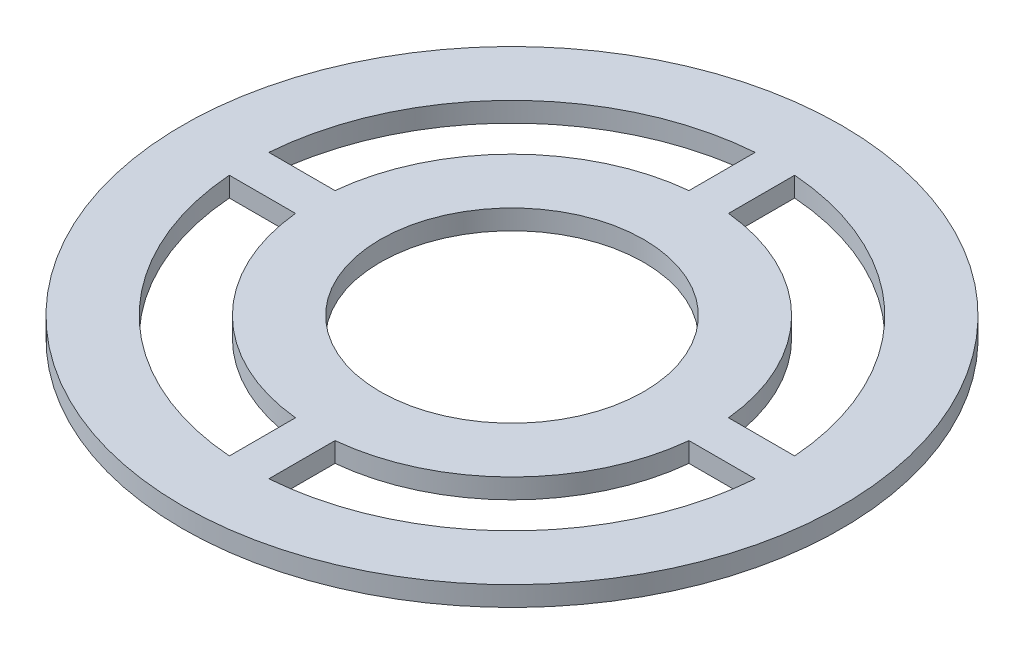
from build123d import *

# Parameters (mm, degrees)
ESQUISSE1_R          = 25
ESQUISSE1_R_2        = 20
BOSS_EXTRU_3_DEPTH   = 1.5
ESQUISSE1_R_3        = 15
ESQUISSE1_R_4        = 10
BOSS_EXTRU_3_2_DEPTH = 1.5
ESQUISSE3_W          = 7
ESQUISSE3_H          = 3
ESQUISSE3_W_2        = 3
ESQUISSE3_H_2        = 7
BOSS_EXTRU_5_DEPTH   = 1.5


with BuildPart() as part:
    # Esquisse1 → Boss.-Extru.3 (new body)
    with BuildSketch(Plane(origin=(0, 0, 0), x_dir=(1, 0, 0), z_dir=(0, 1, 0))):
        Circle(ESQUISSE1_R)
        Circle(ESQUISSE1_R_2, mode=Mode.SUBTRACT)
    extrude(amount=BOSS_EXTRU_3_DEPTH)



with BuildPart() as body_2:
    # Esquisse1 → Boss.-Extru.3 2 (new body)
    with BuildSketch(Plane(origin=(0, 0, 0), x_dir=(1, 0, 0), z_dir=(0, 1, 0))):
        Circle(ESQUISSE1_R_3)
        Circle(ESQUISSE1_R_4, mode=Mode.SUBTRACT)
    extrude(amount=BOSS_EXTRU_3_2_DEPTH)


with BuildPart() as part_1:
    add(part.part)

    add(body_2.part)  # Boss.-Extru.5 merges body 2
    # Esquisse3 → Boss.-Extru.5 (add)
    with BuildSketch(Plane(origin=(0, 1.5, 0), x_dir=(-1, 0, 0), z_dir=(0, 1, 0))):
        with Locations((18.424811557, 0)):
            Rectangle(ESQUISSE3_W, ESQUISSE3_H)
        with Locations((0, -17.5)):
            Rectangle(ESQUISSE3_W_2, ESQUISSE3_H_2)
        with Locations((-17.5, 0)):
            Rectangle(ESQUISSE3_W, ESQUISSE3_H)
        with Locations((0, 17.5)):
            Rectangle(ESQUISSE3_W_2, ESQUISSE3_H_2)
    extrude(amount=-BOSS_EXTRU_5_DEPTH)


solid = part_1.part
